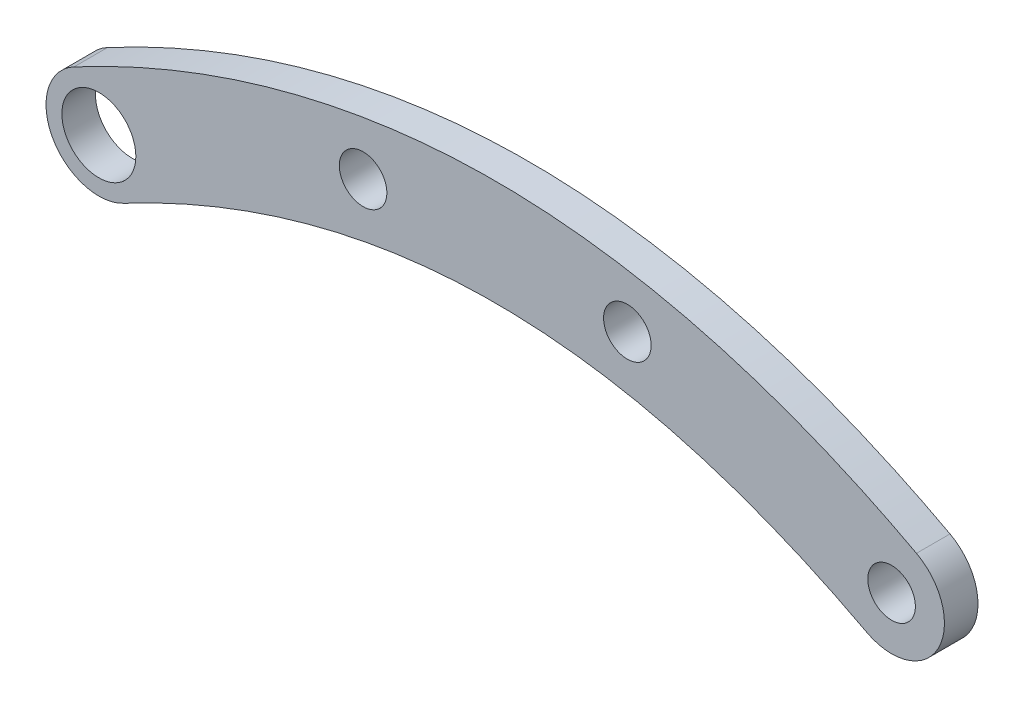
from build123d import *

# Parameters (mm, degrees)
BOSS_EXTRUDE1_DEPTH  = 1.5875
M4_CLEARANCE_HOLE1_D = 4.5
SKETCH5_R            = 3.5
CUT_EXTRUDE1_DEPTH   = 4.1750001


with BuildPart() as part:
    # Sketch1 → Boss-Extrude1 (new body, symmetric)
    with BuildSketch(Plane.XY):
        with BuildLine():
            ThreePointArc((-35.147058824, -14.411764706), (-41.911764706, -12.352941176), (-39.852941176, -5.588235294))
            add(Edge.make_bspline(
                [(-39.852941176, -5.588235294), (-25.087835375, 2.313761515), (0, 5.671559621), (25.087835375, 2.313761515), (39.852941176, -5.588235294)],
                knots=[0, 0, 0, 0.375, 0.625, 1, 1, 1], degree=2))
            ThreePointArc((39.852941176, -5.588235294), (41.911764706, -12.352941176), (35.147058824, -14.411764706))
            add(Edge.make_bspline(
                [(-35.147058824, -14.411764706), (-21.787164625, -7.313761515), (0, -4.421559621), (21.787164625, -7.313761515), (35.147058824, -14.411764706)],
                knots=[0, 0, 0, 0.375, 0.625, 1, 1, 1], degree=2))
        make_face()
    extrude(amount=BOSS_EXTRUDE1_DEPTH, both=True)

    # M4 Clearance Hole1 (through all)
    with Locations(Plane.XY.offset(1.5875)):
        with Locations((37.5, -10), (-12.5, -1.111111111), (12.5, -1.111111111)):
            Hole(M4_CLEARANCE_HOLE1_D / 2)

    # Sketch5 → Cut-Extrude1 (cut, through all)
    with BuildSketch(Plane.XY.offset(1.5875)):
        with Locations((-37.5, -10)):
            Circle(SKETCH5_R)
    extrude(amount=-CUT_EXTRUDE1_DEPTH, mode=Mode.SUBTRACT)


solid = part.part
